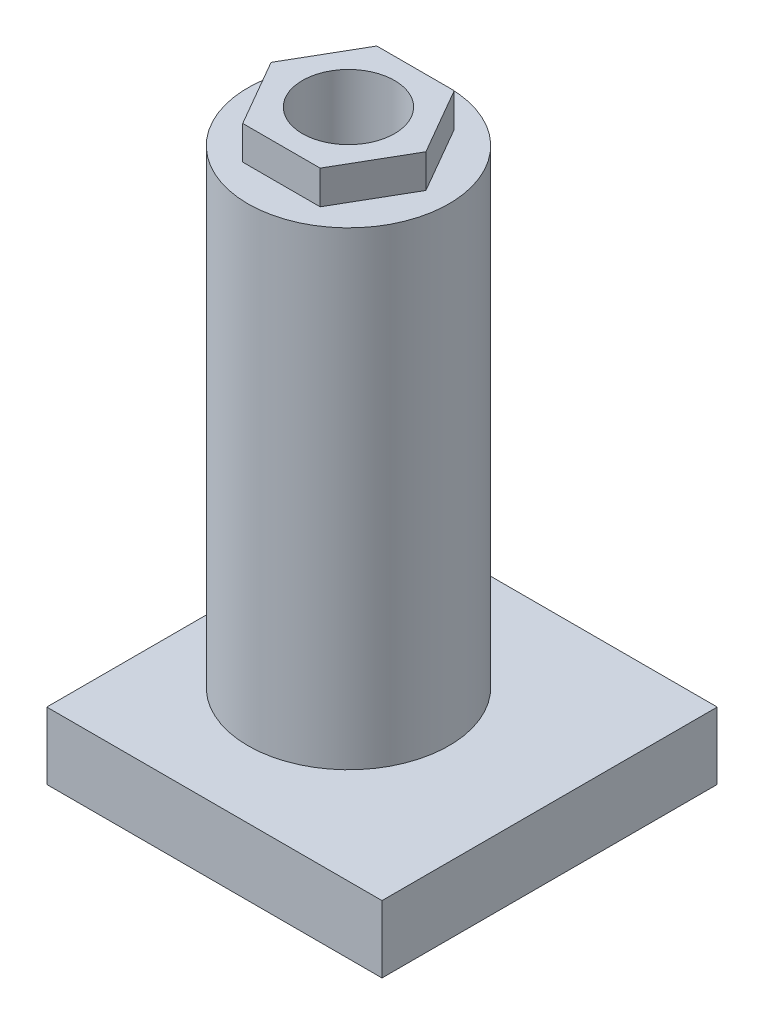
from build123d import *

# Parameters (mm, degrees)
SKETCH1_W           = 127
SKETCH1_H           = 127
BOSS_EXTRUDE1_DEPTH = 25.4
SKETCH2_R           = 38.1
BOSS_EXTRUDE2_DEPTH = 177.8
BOSS_EXTRUDE3_DEPTH = 12.7
SKETCH4_R           = 17.4625
CUT_EXTRUDE1_DEPTH  = 152.4


with BuildPart() as part:
    # Sketch1 → Boss-Extrude1 (new body)
    with BuildSketch(Plane(origin=(0, 0, 0), x_dir=(1, 0, 0), z_dir=(0, 1, 0))):
        Rectangle(SKETCH1_W, SKETCH1_H)
    extrude(amount=BOSS_EXTRUDE1_DEPTH)

    # Sketch2 → Boss-Extrude2 (add)
    with BuildSketch(Plane(origin=(0, 25.4, 0), x_dir=(1, 0, 0), z_dir=(0, 1, 0))):
        with Locations(Location((-12.7, 0, 0), (0, 0, 270))):  # turned: the seam where the file's is
            Circle(SKETCH2_R)
    extrude(amount=BOSS_EXTRUDE2_DEPTH)

    # Sketch3 → Boss-Extrude3 (add)
    with BuildSketch(Plane(origin=(0, 203.2, 0), x_dir=(1, 0, 0), z_dir=(0, 1, 0))):
        Polygon((16.629393675, 0), (1.964696837, 25.4), (-27.364696837, 25.4), (-42.029393675, 0), (-27.364696837, -25.4), (1.964696837, -25.4), align=None)
    extrude(amount=BOSS_EXTRUDE3_DEPTH)

    # Sketch4 → Cut-Extrude1 (cut)
    with BuildSketch(Plane(origin=(0, 215.9, 0), x_dir=(1, 0, 0), z_dir=(0, 1, 0))):
        with Locations(Location((-12.7, 0, 0), (0, 0, 270))):  # turned: the seam where the file's is
            Circle(SKETCH4_R)
    extrude(amount=-CUT_EXTRUDE1_DEPTH, mode=Mode.SUBTRACT)


solid = part.part
